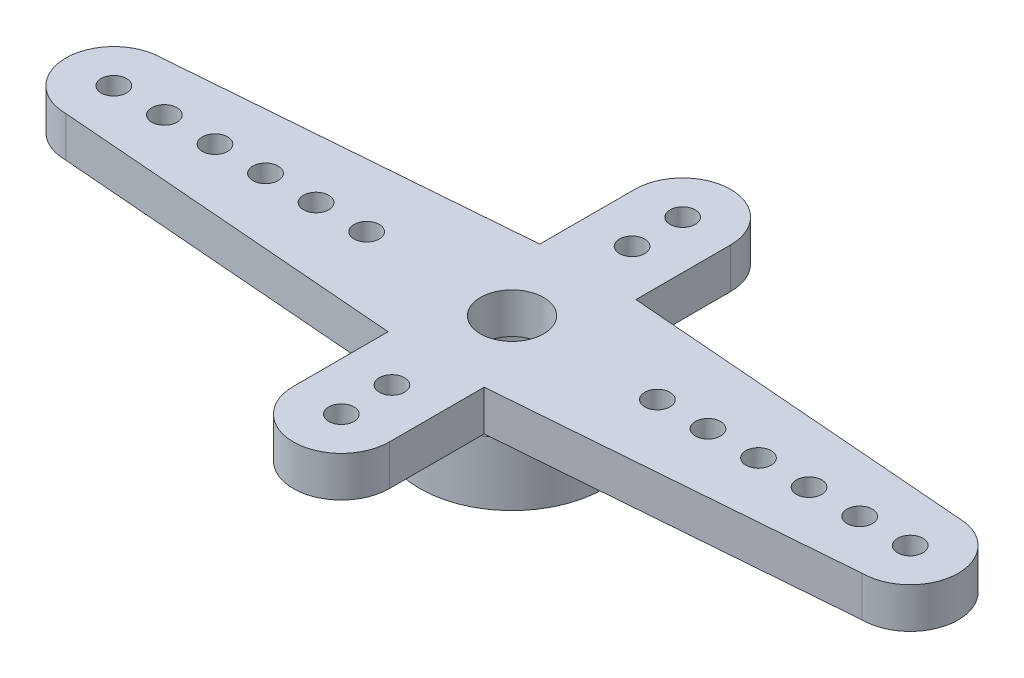
from build123d import *

# Parameters (mm, degrees)
SKETCH1_R           = 3.65
SKETCH1_R_2         = 2.5
BOSS_EXTRUDE1_DEPTH = 2.5
SKETCH2_R           = 1.25
BOSS_EXTRUDE2_DEPTH = 1.6
CUT_EXTRUDE1_REACH  = 6.1
SKETCH3_R           = 0.5


with BuildPart() as part:
    # Sketch1 → Boss-Extrude1 (new body)
    with BuildSketch(Plane(origin=(0, 0, 0), x_dir=(1, 0, 0), z_dir=(0, 1, 0))):
        Circle(SKETCH1_R)
        Circle(SKETCH1_R_2, mode=Mode.SUBTRACT)
    extrude(amount=BOSS_EXTRUDE1_DEPTH)

    # Sketch2 → Boss-Extrude2 (add)
    with BuildSketch(Plane(origin=(0, 2.5, 0), x_dir=(1, 0, 0), z_dir=(0, 1, 0))):
        with BuildLine():
            Line((-1.9, 6.75), (-1.9, 3))
            Line((-1.9, 3), (-15.75, 1.9))
            ThreePointArc((-15.75, 1.9), (-17.65, 0), (-15.75, -1.9))
            Line((-15.75, -1.9), (-1.9, -3))
            Line((-1.9, -3), (-1.9, -6.75))
            ThreePointArc((-1.9, -6.75), (0, -8.65), (1.9, -6.75))
            Line((1.9, -6.75), (1.9, -3))
            Line((1.9, -3), (15.75, -1.9))
            ThreePointArc((15.75, -1.9), (17.65, 0), (15.75, 1.9))
            Line((15.75, 1.9), (1.9, 3))
            Line((1.9, 3), (1.9, 6.75))
            ThreePointArc((1.9, 6.75), (0, 8.65), (-1.9, 6.75))
        make_face()
        Circle(SKETCH2_R, mode=Mode.SUBTRACT)
    extrude(amount=BOSS_EXTRUDE2_DEPTH)

    # Sketch3 → Cut-Extrude1 (cut, up to next)
    with BuildSketch(Plane(origin=(0, 4.1, 0), x_dir=(1, 0, 0), z_dir=(0, 1, 0)), mode=Mode.PRIVATE) as cut_extrude1_sk1:
        with Locations((0, 6.75)):
            Circle(SKETCH3_R)
    cut_extrude1_tool1 = extrude(cut_extrude1_sk1.sketch, amount=-CUT_EXTRUDE1_REACH, mode=Mode.PRIVATE) & part.part
    add(cut_extrude1_tool1.solids().sort_by_distance((0, 4.1, -6.75))[0], mode=Mode.SUBTRACT)
    # Sketch3 → Cut-Extrude1 (cut, up to next)
    with BuildSketch(Plane(origin=(0, 4.1, 0), x_dir=(1, 0, 0), z_dir=(0, 1, 0)), mode=Mode.PRIVATE) as cut_extrude1_sk2:
        with Locations((0, 4.75)):
            Circle(SKETCH3_R)
    cut_extrude1_tool2 = extrude(cut_extrude1_sk2.sketch, amount=-CUT_EXTRUDE1_REACH, mode=Mode.PRIVATE) & part.part
    add(cut_extrude1_tool2.solids().sort_by_distance((0, 4.1, -4.75))[0], mode=Mode.SUBTRACT)
    # Sketch3 → Cut-Extrude1 (cut, up to next)
    with BuildSketch(Plane(origin=(0, 4.1, 0), x_dir=(1, 0, 0), z_dir=(0, 1, 0)), mode=Mode.PRIVATE) as cut_extrude1_sk3:
        with Locations((-15.75, 0)):
            Circle(SKETCH3_R)
    cut_extrude1_tool3 = extrude(cut_extrude1_sk3.sketch, amount=-CUT_EXTRUDE1_REACH, mode=Mode.PRIVATE) & part.part
    add(cut_extrude1_tool3.solids().sort_by_distance((-15.75, 4.1, 0))[0], mode=Mode.SUBTRACT)
    # Sketch3 → Cut-Extrude1 (cut, up to next)
    with BuildSketch(Plane(origin=(0, 4.1, 0), x_dir=(1, 0, 0), z_dir=(0, 1, 0)), mode=Mode.PRIVATE) as cut_extrude1_sk4:
        with Locations((-13.75, 0)):
            Circle(SKETCH3_R)
    cut_extrude1_tool4 = extrude(cut_extrude1_sk4.sketch, amount=-CUT_EXTRUDE1_REACH, mode=Mode.PRIVATE) & part.part
    add(cut_extrude1_tool4.solids().sort_by_distance((-13.75, 4.1, 0))[0], mode=Mode.SUBTRACT)
    # Sketch3 → Cut-Extrude1 (cut, up to next)
    with BuildSketch(Plane(origin=(0, 4.1, 0), x_dir=(1, 0, 0), z_dir=(0, 1, 0)), mode=Mode.PRIVATE) as cut_extrude1_sk5:
        with Locations((-11.75, 0)):
            Circle(SKETCH3_R)
    cut_extrude1_tool5 = extrude(cut_extrude1_sk5.sketch, amount=-CUT_EXTRUDE1_REACH, mode=Mode.PRIVATE) & part.part
    add(cut_extrude1_tool5.solids().sort_by_distance((-11.75, 4.1, 0))[0], mode=Mode.SUBTRACT)
    # Sketch3 → Cut-Extrude1 (cut, up to next)
    with BuildSketch(Plane(origin=(0, 4.1, 0), x_dir=(1, 0, 0), z_dir=(0, 1, 0)), mode=Mode.PRIVATE) as cut_extrude1_sk6:
        with Locations((-9.75, 0)):
            Circle(SKETCH3_R)
    cut_extrude1_tool6 = extrude(cut_extrude1_sk6.sketch, amount=-CUT_EXTRUDE1_REACH, mode=Mode.PRIVATE) & part.part
    add(cut_extrude1_tool6.solids().sort_by_distance((-9.75, 4.1, 0))[0], mode=Mode.SUBTRACT)
    # Sketch3 → Cut-Extrude1 (cut, up to next)
    with BuildSketch(Plane(origin=(0, 4.1, 0), x_dir=(1, 0, 0), z_dir=(0, 1, 0)), mode=Mode.PRIVATE) as cut_extrude1_sk7:
        with Locations((-7.75, 0)):
            Circle(SKETCH3_R)
    cut_extrude1_tool7 = extrude(cut_extrude1_sk7.sketch, amount=-CUT_EXTRUDE1_REACH, mode=Mode.PRIVATE) & part.part
    add(cut_extrude1_tool7.solids().sort_by_distance((-7.75, 4.1, 0))[0], mode=Mode.SUBTRACT)
    # Sketch3 → Cut-Extrude1 (cut, up to next)
    with BuildSketch(Plane(origin=(0, 4.1, 0), x_dir=(1, 0, 0), z_dir=(0, 1, 0)), mode=Mode.PRIVATE) as cut_extrude1_sk8:
        with Locations((-5.75, 0)):
            Circle(SKETCH3_R)
    cut_extrude1_tool8 = extrude(cut_extrude1_sk8.sketch, amount=-CUT_EXTRUDE1_REACH, mode=Mode.PRIVATE) & part.part
    add(cut_extrude1_tool8.solids().sort_by_distance((-5.75, 4.1, 0))[0], mode=Mode.SUBTRACT)
    # Sketch3 → Cut-Extrude1 (cut, up to next)
    with BuildSketch(Plane(origin=(0, 4.1, 0), x_dir=(1, 0, 0), z_dir=(0, 1, 0)), mode=Mode.PRIVATE) as cut_extrude1_sk9:
        with Locations((5.75, 0)):
            Circle(SKETCH3_R)
    cut_extrude1_tool9 = extrude(cut_extrude1_sk9.sketch, amount=-CUT_EXTRUDE1_REACH, mode=Mode.PRIVATE) & part.part
    add(cut_extrude1_tool9.solids().sort_by_distance((5.75, 4.1, 0))[0], mode=Mode.SUBTRACT)
    # Sketch3 → Cut-Extrude1 (cut, up to next)
    with BuildSketch(Plane(origin=(0, 4.1, 0), x_dir=(1, 0, 0), z_dir=(0, 1, 0)), mode=Mode.PRIVATE) as cut_extrude1_sk10:
        with Locations((7.75, 0)):
            Circle(SKETCH3_R)
    cut_extrude1_tool10 = extrude(cut_extrude1_sk10.sketch, amount=-CUT_EXTRUDE1_REACH, mode=Mode.PRIVATE) & part.part
    add(cut_extrude1_tool10.solids().sort_by_distance((7.75, 4.1, 0))[0], mode=Mode.SUBTRACT)
    # Sketch3 → Cut-Extrude1 (cut, up to next)
    with BuildSketch(Plane(origin=(0, 4.1, 0), x_dir=(1, 0, 0), z_dir=(0, 1, 0)), mode=Mode.PRIVATE) as cut_extrude1_sk11:
        with Locations((9.75, 0)):
            Circle(SKETCH3_R)
    cut_extrude1_tool11 = extrude(cut_extrude1_sk11.sketch, amount=-CUT_EXTRUDE1_REACH, mode=Mode.PRIVATE) & part.part
    add(cut_extrude1_tool11.solids().sort_by_distance((9.75, 4.1, 0))[0], mode=Mode.SUBTRACT)
    # Sketch3 → Cut-Extrude1 (cut, up to next)
    with BuildSketch(Plane(origin=(0, 4.1, 0), x_dir=(1, 0, 0), z_dir=(0, 1, 0)), mode=Mode.PRIVATE) as cut_extrude1_sk12:
        with Locations((11.75, 0)):
            Circle(SKETCH3_R)
    cut_extrude1_tool12 = extrude(cut_extrude1_sk12.sketch, amount=-CUT_EXTRUDE1_REACH, mode=Mode.PRIVATE) & part.part
    add(cut_extrude1_tool12.solids().sort_by_distance((11.75, 4.1, 0))[0], mode=Mode.SUBTRACT)
    # Sketch3 → Cut-Extrude1 (cut, up to next)
    with BuildSketch(Plane(origin=(0, 4.1, 0), x_dir=(1, 0, 0), z_dir=(0, 1, 0)), mode=Mode.PRIVATE) as cut_extrude1_sk13:
        with Locations((13.75, 0)):
            Circle(SKETCH3_R)
    cut_extrude1_tool13 = extrude(cut_extrude1_sk13.sketch, amount=-CUT_EXTRUDE1_REACH, mode=Mode.PRIVATE) & part.part
    add(cut_extrude1_tool13.solids().sort_by_distance((13.75, 4.1, 0))[0], mode=Mode.SUBTRACT)
    # Sketch3 → Cut-Extrude1 (cut, up to next)
    with BuildSketch(Plane(origin=(0, 4.1, 0), x_dir=(1, 0, 0), z_dir=(0, 1, 0)), mode=Mode.PRIVATE) as cut_extrude1_sk14:
        with Locations((15.75, 0)):
            Circle(SKETCH3_R)
    cut_extrude1_tool14 = extrude(cut_extrude1_sk14.sketch, amount=-CUT_EXTRUDE1_REACH, mode=Mode.PRIVATE) & part.part
    add(cut_extrude1_tool14.solids().sort_by_distance((15.75, 4.1, 0))[0], mode=Mode.SUBTRACT)
    # Sketch3 → Cut-Extrude1 (cut, up to next)
    with BuildSketch(Plane(origin=(0, 4.1, 0), x_dir=(1, 0, 0), z_dir=(0, 1, 0)), mode=Mode.PRIVATE) as cut_extrude1_sk15:
        with Locations((0, -4.75)):
            Circle(SKETCH3_R)
    cut_extrude1_tool15 = extrude(cut_extrude1_sk15.sketch, amount=-CUT_EXTRUDE1_REACH, mode=Mode.PRIVATE) & part.part
    add(cut_extrude1_tool15.solids().sort_by_distance((0, 4.1, 4.75))[0], mode=Mode.SUBTRACT)
    # Sketch3 → Cut-Extrude1 (cut, up to next)
    with BuildSketch(Plane(origin=(0, 4.1, 0), x_dir=(1, 0, 0), z_dir=(0, 1, 0)), mode=Mode.PRIVATE) as cut_extrude1_sk16:
        with Locations((0, -6.75)):
            Circle(SKETCH3_R)
    cut_extrude1_tool16 = extrude(cut_extrude1_sk16.sketch, amount=-CUT_EXTRUDE1_REACH, mode=Mode.PRIVATE) & part.part
    add(cut_extrude1_tool16.solids().sort_by_distance((0, 4.1, 6.75))[0], mode=Mode.SUBTRACT)


solid = part.part
